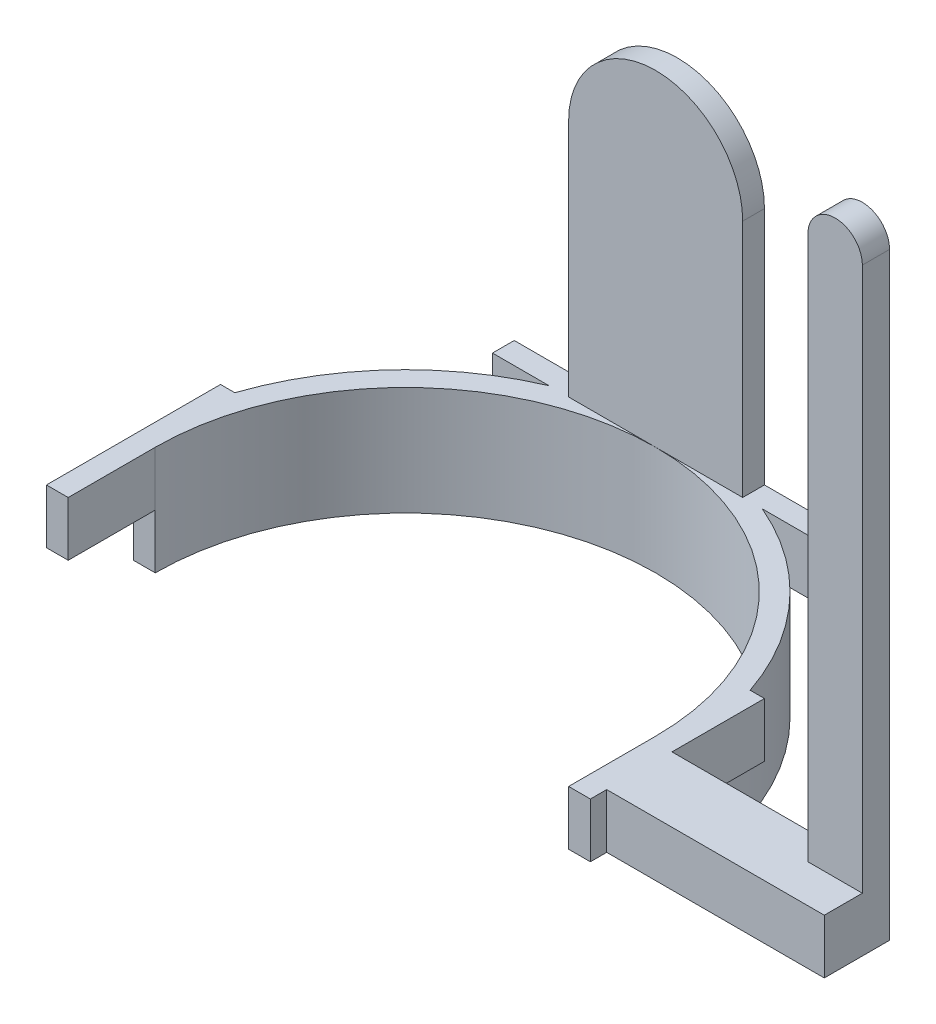
from build123d import *

# Parameters (mm, degrees)
EXTRUDE_1_DEPTH     = 10
EXTRUDE_2_DEPTH     = 10
SKETCH_4_W          = 32
SKETCH_4_H          = 4
EXTRUDE_3_DEPTH     = 60
CUT_EXTRUDE_1_DEPTH = 30
SKETCH_6_W          = 12
SKETCH_6_H          = 10
EXTRUDE_4_DEPTH     = 40
SKETCH_7_W          = 10
SKETCH_7_H          = 5
EXTRUDE_5_DEPTH     = 100
SKETCH_8_R          = 5
EXTRUDE_6_DEPTH     = 5


with BuildPart() as part:
    # 草图1 → 凸台-拉伸1 (new body)
    with BuildSketch(Plane(origin=(0, 0, 0), x_dir=(1, 0, 0), z_dir=(0, 1, 0))):
        with BuildLine():
            Line((-50, 0), (-46, 0))
            ThreePointArc((-46, 0), (0, 46), (46, 0))
            Line((46, 0), (50, 0))
            ThreePointArc((50, 0), (0, 50), (-50, 0))
        make_face()
    extrude(amount=EXTRUDE_1_DEPTH)

    # 草图3 → 凸台-拉伸2 (add)
    with BuildSketch(Plane(origin=(0, 10, 0), x_dir=(1, 0, 0), z_dir=(0, 1, 0))):
        with BuildLine():
            Line((-50, 16), (-47.370877129, 16))
            ThreePointArc((-47.370877129, 16), (-36.689752119, 33.968545589), (-19.595917942, 46))
            Line((-19.595917942, 46), (-30, 46))
            Line((-30, 46), (-30, 50))
            Line((-30, 50), (30, 50))
            Line((30, 50), (30, 46))
            Line((30, 46), (19.595917942, 46))
            ThreePointArc((19.595917942, 46), (36.689752119, 33.968545589), (47.370877129, 16))
            Line((47.370877129, 16), (50, 16))
            Line((50, 16), (50, -16))
            Line((50, -16), (46, -16))
            Line((46, -16), (46, 0))
            ThreePointArc((46, 0), (0, 46), (-46, 0))
            Line((-46, 0), (-46, -16))
            Line((-46, -16), (-50, -16))
            Line((-50, -16), (-50, 16))
        make_face()
    extrude(amount=EXTRUDE_2_DEPTH)

    # 草图4 → 凸台-拉伸3 (add)
    with BuildSketch(Plane(origin=(0, 20, 0), x_dir=(1, 0, 0), z_dir=(0, 1, 0))):
        with Locations((0, 48)):
            Rectangle(SKETCH_4_W, SKETCH_4_H)
    extrude(amount=EXTRUDE_3_DEPTH)

    # 草图5 → 切除-拉伸1 (cut)
    with BuildSketch(Plane(origin=(0, 0, -50), x_dir=(-1, 0, 0), z_dir=(0, 0, -1))):
        with BuildLine():
            Line((-16, 64), (-16, 97.905328476))
            Line((-16, 97.905328476), (16, 97.905328476))
            Line((16, 97.905328476), (16, 64))
            ThreePointArc((16, 64), (0, 80), (-16, 64))
        make_face()
    extrude(amount=-CUT_EXTRUDE_1_DEPTH, mode=Mode.SUBTRACT)

    # 草图6 → 凸台-拉伸4 (add)
    with BuildSketch(Plane(origin=(50, 0, 0), x_dir=(0, 0, -1), z_dir=(1, 0, 0))):
        with Locations((-7, 15)):
            Rectangle(SKETCH_6_W, SKETCH_6_H)
    extrude(amount=EXTRUDE_4_DEPTH)

    # 草图7 → 凸台-拉伸5 (add)
    with BuildSketch(Plane(origin=(0, 20, 0), x_dir=(1, 0, 0), z_dir=(0, 1, 0))):
        with Locations((85, -3.5)):
            Rectangle(SKETCH_7_W, SKETCH_7_H)
    extrude(amount=EXTRUDE_5_DEPTH)

    # 草图8 → 凸台-拉伸6 (add)
    with BuildSketch(Plane(origin=(0, 0, 1), x_dir=(-1, 0, 0), z_dir=(0, 0, -1))):
        with Locations((-85, 120)):
            Circle(SKETCH_8_R)
    extrude(amount=-EXTRUDE_6_DEPTH)


solid = part.part
